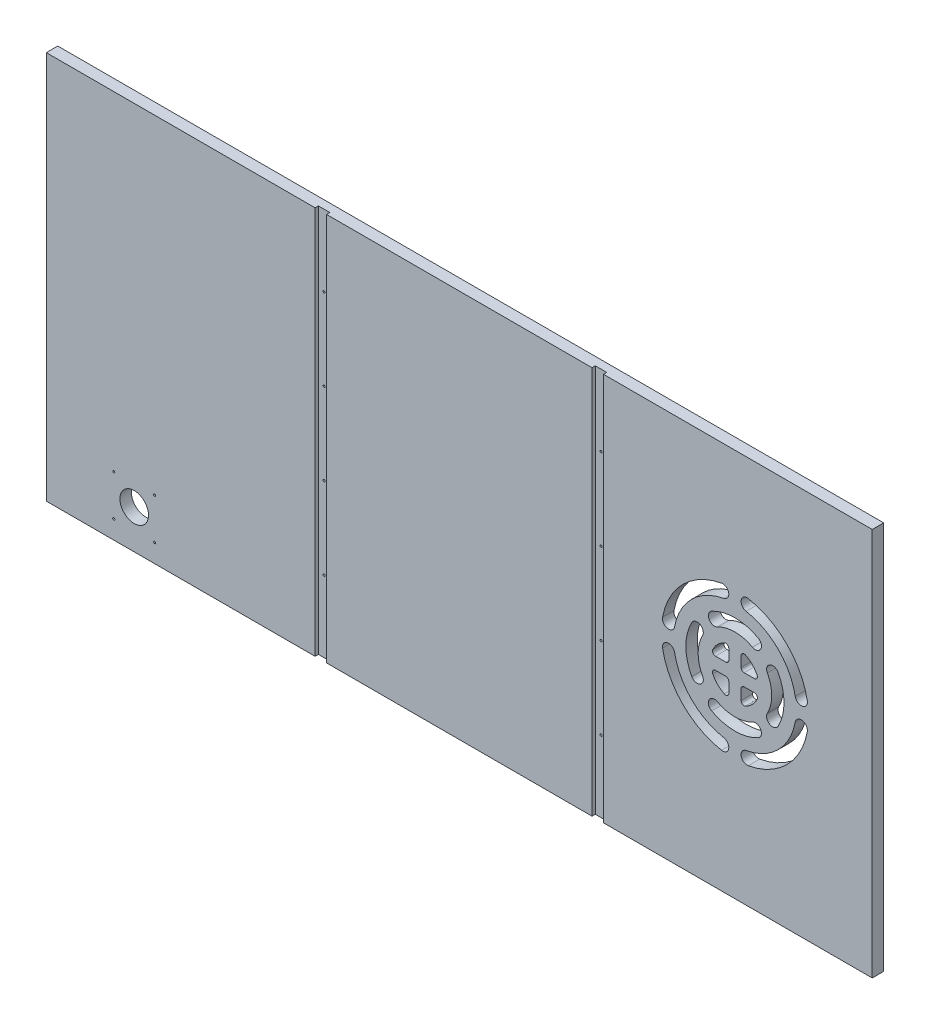
from build123d import *

# Parameters (mm, degrees)
CABBOTTOM_OUTLINE_W       = 1282.7
CABBOTTOM_OUTLINE_H       = 603.25
CABBOTTOM_THICKNESS_DEPTH = 17.78
SKETCH4_R                 = 22.225
SKETCH4_R_2               = 1.5875
SKETCH4_R_3               = 1.628860789
SKETCH4_R_4               = 1.721410862
CUT_EXTRUDE1_DEPTH        = 17.78
BRACECUTS_DEPTH_DEPTH     = 5.08


with BuildPart() as part:
    # CabBottom_Outline → CabBottom_Thickness (new body)
    with BuildSketch(Plane.XY):
        with Locations((9556.220833334, -6075.3625)):
            Rectangle(CABBOTTOM_OUTLINE_W, CABBOTTOM_OUTLINE_H)
    extrude(amount=-CABBOTTOM_THICKNESS_DEPTH)

    # Sketch4 → Cut-Extrude1 (cut)
    with BuildSketch(Plane.XY):
        with Locations((9051.395833334, -6316.6625)):
            Circle(SKETCH4_R)
        with Locations((9019.645833334, -6284.9125)):
            Circle(SKETCH4_R_2)
        with Locations((9083.145833334, -6284.9125)):
            Circle(SKETCH4_R_2)
        with Locations((9083.145833334, -6348.4125)):
            Circle(SKETCH4_R_3)
        with Locations((9019.645833334, -6348.4125)):
            Circle(SKETCH4_R_4)
        with Locations((9341.1675, -6265.8625)):
            Circle(SKETCH4_R_2)
        with Locations((9341.1675, -6138.8625)):
            Circle(SKETCH4_R_2)
        with Locations((9341.1675, -6011.8625)):
            Circle(SKETCH4_R_2)
        with Locations((9341.1675, -5884.8625)):
            Circle(SKETCH4_R_2)
        with Locations((9771.274166666, -5884.8625)):
            Circle(SKETCH4_R_2)
        with Locations((9771.274166666, -6011.8625)):
            Circle(SKETCH4_R_2)
        with Locations((9771.274166666, -6138.8625)):
            Circle(SKETCH4_R_2)
        with Locations((9771.274166666, -6265.8625)):
            Circle(SKETCH4_R_2)
        with BuildLine():
            Line((9974.787433334, -6061.075), (9974.787433334, -6045.241805286))
            ThreePointArc((9974.787433334, -6045.241805286), (9972.570596663, -6041.216758148), (9967.983861906, -6040.938848899))
            ThreePointArc((9967.983861906, -6040.938848899), (9957.371664972, -6048.421731638), (9949.888782233, -6059.033928571))
            ThreePointArc((9949.888782233, -6059.033928571), (9950.166691482, -6063.620663329), (9954.19173862, -6065.8375))
            Line((9954.19173862, -6065.8375), (9970.024933334, -6065.8375))
            ThreePointArc((9970.024933334, -6065.8375), (9973.39252938, -6064.442596045), (9974.787433334, -6061.075))
        make_face()
        with BuildLine():
            Line((9993.837433334, -6045.241805286), (9993.837433334, -6061.075))
            ThreePointArc((9993.837433334, -6061.075), (9995.232337289, -6064.442596045), (9998.599933334, -6065.8375))
            Line((9998.599933334, -6065.8375), (10014.433128046, -6065.8375))
            ThreePointArc((10014.433128046, -6065.8375), (10018.458175184, -6063.620663329), (10018.736084433, -6059.033928571))
            ThreePointArc((10018.736084433, -6059.033928571), (10011.253201696, -6048.421731637), (10000.641004763, -6040.938848899))
            ThreePointArc((10000.641004763, -6040.938848899), (9996.054270005, -6041.216758148), (9993.837433334, -6045.241805286))
        make_face()
        with BuildLine():
            Line((10014.433128046, -6084.8875), (9998.599933334, -6084.8875))
            ThreePointArc((9998.599933334, -6084.8875), (9995.232337289, -6086.282403955), (9993.837433334, -6089.65))
            Line((9993.837433334, -6089.65), (9993.837433334, -6105.483194714))
            ThreePointArc((9993.837433334, -6105.483194714), (9996.054270005, -6109.508241852), (10000.641004763, -6109.786151102))
            ThreePointArc((10000.641004763, -6109.786151102), (10011.253201699, -6102.303268365), (10018.736084435, -6091.691071429))
            ThreePointArc((10018.736084435, -6091.691071429), (10018.458175184, -6087.104336671), (10014.433128046, -6084.8875))
        make_face()
        with BuildLine():
            Line((9970.024933334, -6084.8875), (9954.19173862, -6084.8875))
            ThreePointArc((9954.19173862, -6084.8875), (9950.166691482, -6087.104336671), (9949.888782233, -6091.691071429))
            ThreePointArc((9949.888782233, -6091.691071429), (9957.371664972, -6102.303268362), (9967.983861906, -6109.786151101))
            ThreePointArc((9967.983861906, -6109.786151101), (9972.570596663, -6109.508241852), (9974.787433334, -6105.483194714))
            Line((9974.787433334, -6105.483194714), (9974.787433334, -6089.65))
            ThreePointArc((9974.787433334, -6089.65), (9973.39252938, -6086.282403955), (9970.024933334, -6084.8875))
        make_face()
        with BuildLine():
            ThreePointArc((9890.650044519, -6058.044318182), (9916.960512426, -6008.010579092), (9966.994251516, -5981.700111185))
            ThreePointArc((9966.994251516, -5981.700111185), (9972.584359078, -5978.426082773), (9974.787433334, -5972.333872304))
            ThreePointArc((9974.787433334, -5972.333872304), (9971.354643804, -5965.01194656), (9963.530615152, -5962.967633422))
            ThreePointArc((9963.530615152, -5962.967633422), (9903.490128244, -5994.54019491), (9871.917566756, -6054.580681818))
            ThreePointArc((9871.917566756, -6054.580681818), (9879.551987456, -6065.678738882), (9890.650044519, -6058.044318182))
        make_face()
        with BuildLine():
            ThreePointArc((9890.650044519, -6092.680681818), (9916.960512426, -6142.714420908), (9966.994251516, -6169.024888814))
            ThreePointArc((9966.994251516, -6169.024888814), (9974.628672216, -6180.122945878), (9963.530615152, -6187.757366578))
            ThreePointArc((9963.530615152, -6187.757366578), (9903.490128244, -6156.18480509), (9871.917566756, -6096.144318182))
            ThreePointArc((9871.917566756, -6096.144318182), (9879.551987456, -6085.046261119), (9890.650044519, -6092.680681818))
        make_face()
        with BuildLine():
            ThreePointArc((10001.630615152, -6169.024888815), (10051.664354242, -6142.714420908), (10077.974822149, -6092.680681818))
            ThreePointArc((10077.974822149, -6092.680681818), (10089.072879212, -6085.046261118), (10096.707299912, -6096.144318182))
            ThreePointArc((10096.707299912, -6096.144318182), (10065.134738424, -6156.18480509), (10005.094251516, -6187.757366578))
            ThreePointArc((10005.094251516, -6187.757366578), (9993.996194453, -6180.122945878), (10001.630615152, -6169.024888815))
        make_face()
        with BuildLine():
            ThreePointArc((10001.630615152, -5981.700111185), (10051.664354242, -6008.010579092), (10077.974822148, -6058.044318182))
            ThreePointArc((10077.974822148, -6058.044318182), (10089.072879212, -6065.678738882), (10096.707299912, -6054.580681818))
            ThreePointArc((10096.707299912, -6054.580681818), (10065.134738424, -5994.54019491), (10005.094251516, -5962.967633422))
            ThreePointArc((10005.094251516, -5962.967633422), (9993.996194453, -5970.602054122), (10001.630615152, -5981.700111185))
        make_face()
        with BuildLine():
            ThreePointArc((9917.282231904, -6111.603251872), (9908.112433335, -6075.3625), (9917.282231902, -6039.121748127))
            ThreePointArc((9917.282231902, -6039.121748127), (9930.191101067, -6035.273066932), (9934.039782262, -6048.181936096))
            ThreePointArc((9934.039782262, -6048.181936096), (9927.162433334, -6075.3625), (9934.039782262, -6102.543063904))
            ThreePointArc((9934.039782262, -6102.543063904), (9930.191101067, -6115.451933067), (9917.282231904, -6111.603251872))
        make_face()
        with BuildLine():
            ThreePointArc((9948.071681461, -6008.332298571), (9984.312433334, -5999.162499998), (10020.553185206, -6008.33229857))
            ThreePointArc((10020.553185206, -6008.33229857), (10024.4018664, -6021.241167734), (10011.492997237, -6025.089848928))
            ThreePointArc((10011.492997237, -6025.089848928), (9984.312433333, -6018.212500001), (9957.131869429, -6025.089848928))
            ThreePointArc((9957.131869429, -6025.089848928), (9944.223000266, -6021.241167734), (9948.071681461, -6008.332298571))
        make_face()
        with BuildLine():
            ThreePointArc((10020.553185206, -6142.39270143), (9984.312433334, -6151.5625), (9948.071681462, -6142.39270143))
            ThreePointArc((9948.071681462, -6142.39270143), (9944.223000267, -6129.483832267), (9957.13186943, -6125.635151072))
            ThreePointArc((9957.13186943, -6125.635151072), (9984.312433334, -6132.5125), (10011.492997238, -6125.635151072))
            ThreePointArc((10011.492997238, -6125.635151072), (10024.401866401, -6129.483832267), (10020.553185206, -6142.39270143))
        make_face()
        with BuildLine():
            ThreePointArc((10051.342634764, -6039.121748128), (10060.512433334, -6075.362500001), (10051.342634763, -6111.603251873))
            ThreePointArc((10051.342634763, -6111.603251873), (10038.43373034, -6115.45201683), (10034.585084407, -6102.543063904))
            ThreePointArc((10034.585084407, -6102.543063904), (10041.481320453, -6075.344350738), (10034.638263059, -6048.132209422))
            ThreePointArc((10034.638263059, -6048.132209422), (10038.489595862, -6035.282908491), (10051.342634764, -6039.121748128))
        make_face()
    extrude(amount=-CUT_EXTRUDE1_DEPTH, mode=Mode.SUBTRACT)

    # BraceCuts → BraceCuts_Depth (cut)
    with BuildSketch(Plane.XY):
        Polygon((9350.0575, -6075.3625), (9350.0575, -5773.7375), (9332.2775, -5773.7375), (9332.2775, -6376.9875), (9350.0575, -6376.9875), align=None)
        Polygon((9762.384166666, -6075.3625), (9762.384166666, -6376.9875), (9780.164166666, -6376.9875), (9780.164166666, -5773.7375), (9762.384166666, -5773.7375), align=None)
    extrude(amount=-BRACECUTS_DEPTH_DEPTH, mode=Mode.SUBTRACT)


solid = part.part
